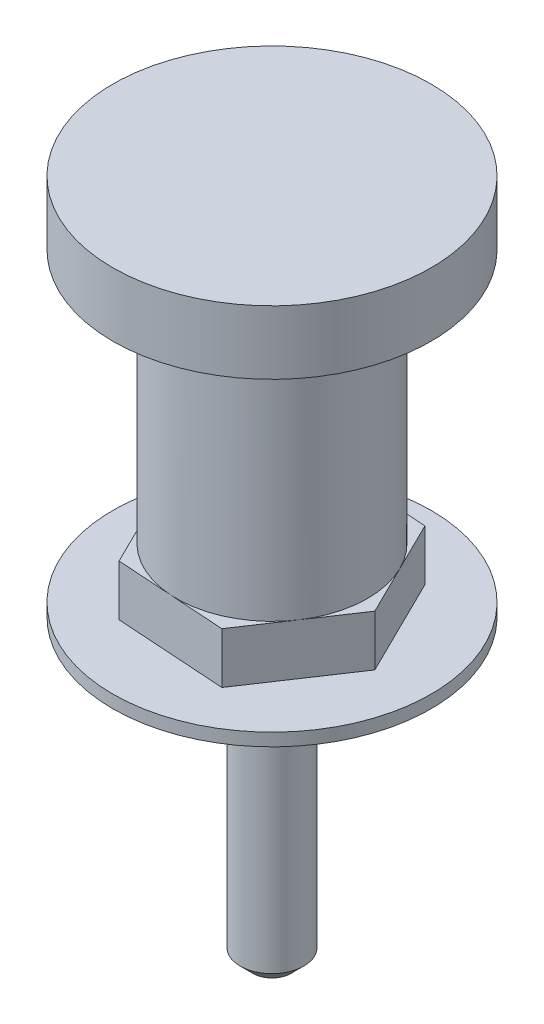
from build123d import *

# Parameters (mm, degrees)
SKETCH1_R           = 12.5
BOSS_EXTRUDE1_DEPTH = 1
BOSS_EXTRUDE2_DEPTH = 4
SKETCH4_R           = 2.5
BOSS_EXTRUDE3_DEPTH = 28.5
CHAMFER1_SIZE       = 1
SKETCH5_R           = 7.5
BOSS_EXTRUDE4_DEPTH = 20
SKETCH6_R           = 12.5
BOSS_EXTRUDE5_DEPTH = 5


with BuildPart() as part:
    # Sketch1 → Boss-Extrude1 (new body)
    with BuildSketch(Plane(origin=(0, 0, 0), x_dir=(1, 0, 0), z_dir=(0, 1, 0))):
        Circle(SKETCH1_R)
    extrude(amount=BOSS_EXTRUDE1_DEPTH)

    # Sketch2 → Boss-Extrude2 (add)
    with BuildSketch(Plane(origin=(0, 1, 0), x_dir=(1, 0, 0), z_dir=(0, 1, 0))):
        Polygon((3.830656369, -7.766986017), (8.641735386, -0.56604728), (4.811079017, 7.200938737), (-3.830656369, 7.766986017), (-8.641735386, 0.56604728), (-4.811079017, -7.200938737), align=None)
    extrude(amount=BOSS_EXTRUDE2_DEPTH)

    # Sketch4 → Boss-Extrude3 (add)
    with BuildSketch(Plane(origin=(0, 5, 0), x_dir=(1, 0, 0), z_dir=(0, 1, 0))):
        Circle(SKETCH4_R)
    extrude(amount=-BOSS_EXTRUDE3_DEPTH)

    # Chamfer1
    chamfer1_edges = [part.edges().sort_by_distance(p)[0] for p in [
        (-2.5, -23.5, 0),
    ]]
    chamfer(chamfer1_edges, length=CHAMFER1_SIZE)

    # Sketch5 → Boss-Extrude4 (add)
    with BuildSketch(Plane(origin=(0, 5, 0), x_dir=(1, 0, 0), z_dir=(0, 1, 0))):
        Circle(SKETCH5_R)
    extrude(amount=BOSS_EXTRUDE4_DEPTH)

    # Sketch6 → Boss-Extrude5 (add)
    with BuildSketch(Plane(origin=(0, 25, 0), x_dir=(1, 0, 0), z_dir=(0, 1, 0))):
        Circle(SKETCH6_R)
    extrude(amount=BOSS_EXTRUDE5_DEPTH)


solid = part.part
